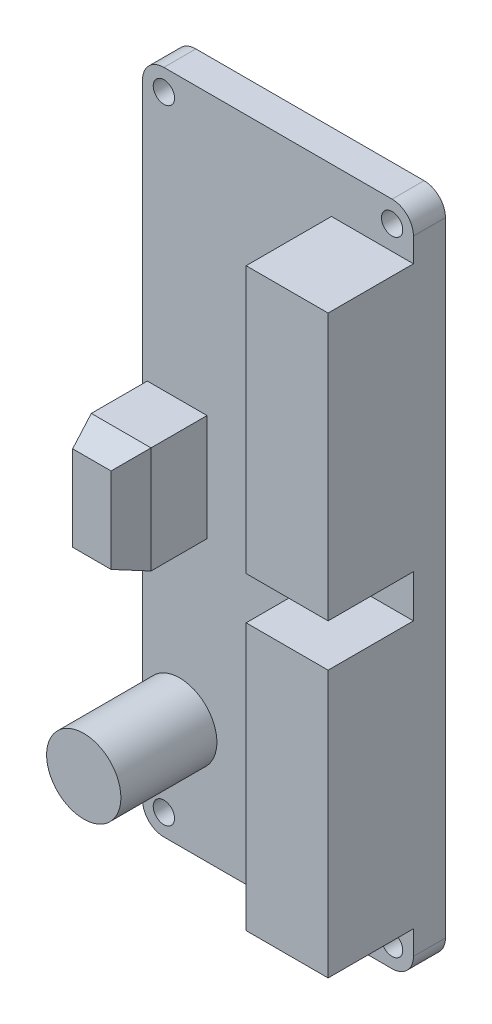
from build123d import *

# Parameters (mm, degrees)
BOSS_EXTRUDE2_DEPTH = 3
CUT_EXTRUDE1_REACH  = 5
SKETCH2_R           = 1
SKETCH3_W           = 5.601007624
SKETCH3_H           = 10
BOSS_EXTRUDE3_DEPTH = 8
CHAMFER1_SIZE       = 1
CHAMFER1_SIZE2      = 2.747477419
CHAMFER2_SIZE       = 1
CHAMFER2_SIZE2      = 2.747477419
CHAMFER3_SIZE       = 1
CHAMFER3_SIZE2      = 2.747477419
CHAMFER4_SIZE       = 1
CHAMFER4_SIZE2      = 2.747477419
SKETCH4_W           = 7.688117752
SKETCH4_H           = 25
BOSS_EXTRUDE4_DEPTH = 8
SKETCH5_R           = 3.48412519
BOSS_EXTRUDE5_DEPTH = 9


with BuildPart() as part:
    # Sketch1 → Boss-Extrude2 (new body)
    with BuildSketch(Plane.XY):
        with BuildLine():
            Line((-10.7, 31.25), (10.7, 31.25))
            ThreePointArc((10.7, 31.25), (12.114213562, 30.664213562), (12.7, 29.25))
            Line((12.7, 29.25), (12.7, -29.25))
            ThreePointArc((12.7, -29.25), (12.114213562, -30.664213562), (10.7, -31.25))
            Line((10.7, -31.25), (-10.7, -31.25))
            ThreePointArc((-10.7, -31.25), (-12.114213562, -30.664213562), (-12.7, -29.25))
            Line((-12.7, -29.25), (-12.7, 29.25))
            ThreePointArc((-12.7, 29.25), (-12.114213562, 30.664213562), (-10.7, 31.25))
        make_face()
    extrude(amount=BOSS_EXTRUDE2_DEPTH)

    # Sketch2 → Cut-Extrude1 (cut, up to next)
    with BuildSketch(Plane.XY.offset(3), mode=Mode.PRIVATE) as cut_extrude1_sk1:
        with Locations((-10.7, 29.25)):
            Circle(SKETCH2_R)
    cut_extrude1_tool1 = extrude(cut_extrude1_sk1.sketch, amount=-CUT_EXTRUDE1_REACH, mode=Mode.PRIVATE) & part.part
    add(cut_extrude1_tool1.solids().sort_by_distance((-10.7, 29.25, 3))[0], mode=Mode.SUBTRACT)
    # Sketch2 → Cut-Extrude1 (cut, up to next)
    with BuildSketch(Plane.XY.offset(3), mode=Mode.PRIVATE) as cut_extrude1_sk2:
        with Locations((10.7, 29.25)):
            Circle(SKETCH2_R)
    cut_extrude1_tool2 = extrude(cut_extrude1_sk2.sketch, amount=-CUT_EXTRUDE1_REACH, mode=Mode.PRIVATE) & part.part
    add(cut_extrude1_tool2.solids().sort_by_distance((10.7, 29.25, 3))[0], mode=Mode.SUBTRACT)
    # Sketch2 → Cut-Extrude1 (cut, up to next)
    with BuildSketch(Plane.XY.offset(3), mode=Mode.PRIVATE) as cut_extrude1_sk3:
        with Locations((10.7, -29.25)):
            Circle(SKETCH2_R)
    cut_extrude1_tool3 = extrude(cut_extrude1_sk3.sketch, amount=-CUT_EXTRUDE1_REACH, mode=Mode.PRIVATE) & part.part
    add(cut_extrude1_tool3.solids().sort_by_distance((10.7, -29.25, 3))[0], mode=Mode.SUBTRACT)
    # Sketch2 → Cut-Extrude1 (cut, up to next)
    with BuildSketch(Plane.XY.offset(3), mode=Mode.PRIVATE) as cut_extrude1_sk4:
        with Locations((-10.7, -29.25)):
            Circle(SKETCH2_R)
    cut_extrude1_tool4 = extrude(cut_extrude1_sk4.sketch, amount=-CUT_EXTRUDE1_REACH, mode=Mode.PRIVATE) & part.part
    add(cut_extrude1_tool4.solids().sort_by_distance((-10.7, -29.25, 3))[0], mode=Mode.SUBTRACT)

    # Sketch3 → Boss-Extrude3 (add)
    with BuildSketch(Plane.XY.offset(3)):
        with Locations((-9.454083627, 0)):
            Rectangle(SKETCH3_W, SKETCH3_H)
    extrude(amount=BOSS_EXTRUDE3_DEPTH)

    # Chamfer1
    chamfer1_edges = [part.edges().sort_by_distance(p)[0] for p in [
        (-9.454083627, -5, 11),
    ]]
    chamfer1_side = [part.faces().sort_by_distance(p)[0] for p in [
        (-9.454083627, 0, 11),
    ]]
    chamfer(chamfer1_edges, length=CHAMFER1_SIZE, length2=CHAMFER1_SIZE2, reference=chamfer1_side[0])

    # Chamfer2
    chamfer2_edges = [part.edges().sort_by_distance(p)[0] for p in [
        (-9.454083627, 5, 11),
    ]]
    chamfer2_side = [part.faces().sort_by_distance(p)[0] for p in [
        (-9.454083627, 0.5, 11),
    ]]
    chamfer(chamfer2_edges, length=CHAMFER2_SIZE, length2=CHAMFER2_SIZE2, reference=chamfer2_side[0])

    # Chamfer3
    chamfer3_edges = [part.edges().sort_by_distance(p)[0] for p in [
        (-12.254587439, 0, 11),
    ]]
    chamfer3_side = [part.faces().sort_by_distance(p)[0] for p in [
        (-9.454083627, 0, 11),
    ]]
    chamfer(chamfer3_edges, length=CHAMFER3_SIZE, length2=CHAMFER3_SIZE2, reference=chamfer3_side[0])

    # Chamfer4
    chamfer4_edges = [part.edges().sort_by_distance(p)[0] for p in [
        (-6.653579815, 0, 11),
    ]]
    chamfer4_side = [part.faces().sort_by_distance(p)[0] for p in [
        (-8.954083627, 0, 11),
    ]]
    chamfer(chamfer4_edges, length=CHAMFER4_SIZE, length2=CHAMFER4_SIZE2, reference=chamfer4_side[0])

    # Sketch4 → Boss-Extrude4 (add)
    with BuildSketch(Plane.XY.offset(3)):
        with Locations((8.855941124, -14.499959716)):
            Rectangle(SKETCH4_W, SKETCH4_H)
        with Locations((8.855941124, 14.499959716)):
            Rectangle(SKETCH4_W, SKETCH4_H)
    extrude(amount=BOSS_EXTRUDE4_DEPTH)

    # Sketch5 → Boss-Extrude5 (add)
    with BuildSketch(Plane.XY.offset(3)):
        with Locations((-9.21587481, -21.073650693)):
            Circle(SKETCH5_R)
    extrude(amount=BOSS_EXTRUDE5_DEPTH)


solid = part.part
